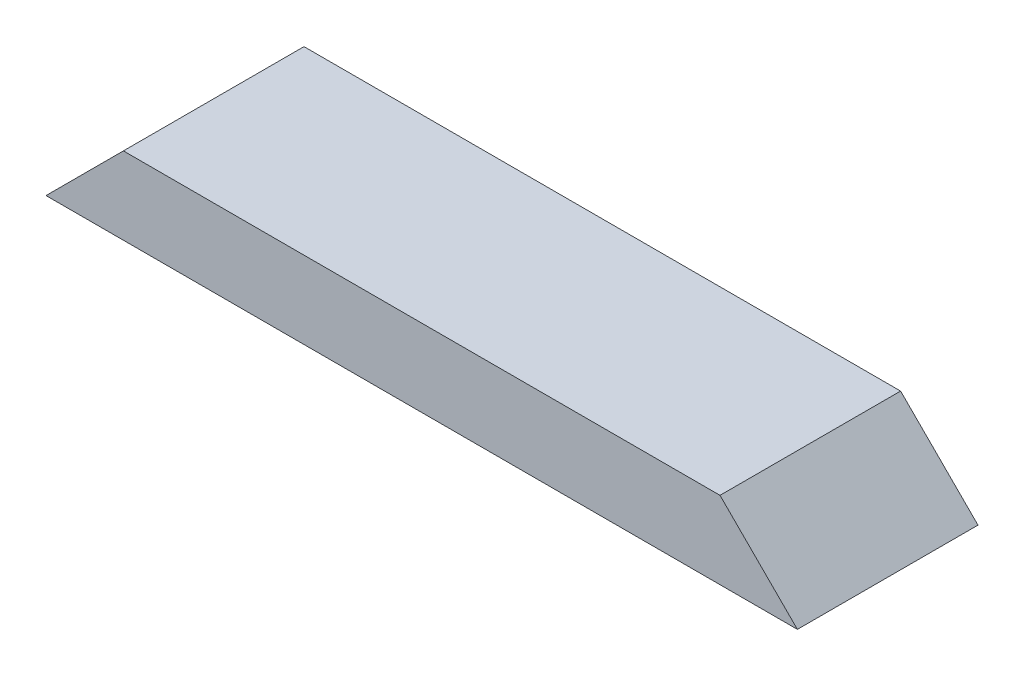
from build123d import *

# Parameters (mm, degrees)
SKETCH1_W           = 369.8875
SKETCH1_H           = 88.9
BOSS_EXTRUDE1_DEPTH = 38.1
CUT_EXTRUDE1_DEPTH  = 89.9


with BuildPart() as part:
    # Sketch1 → Boss-Extrude1 (new body)
    with BuildSketch(Plane(origin=(0, 0, 0), x_dir=(1, 0, 0), z_dir=(0, 1, 0))):
        with Locations((184.94375, 44.45)):
            Rectangle(SKETCH1_W, SKETCH1_H)
    extrude(amount=BOSS_EXTRUDE1_DEPTH)

    # Sketch2 → Cut-Extrude1 (cut, through all)
    with BuildSketch(Plane.XY):
        Polygon((0, 0), (38.1, 38.1), (0, 38.1), align=None)
        Polygon((369.8875, 0), (331.7875, 38.1), (369.8875, 38.1), align=None)
    extrude(amount=-CUT_EXTRUDE1_DEPTH, mode=Mode.SUBTRACT)


solid = part.part
